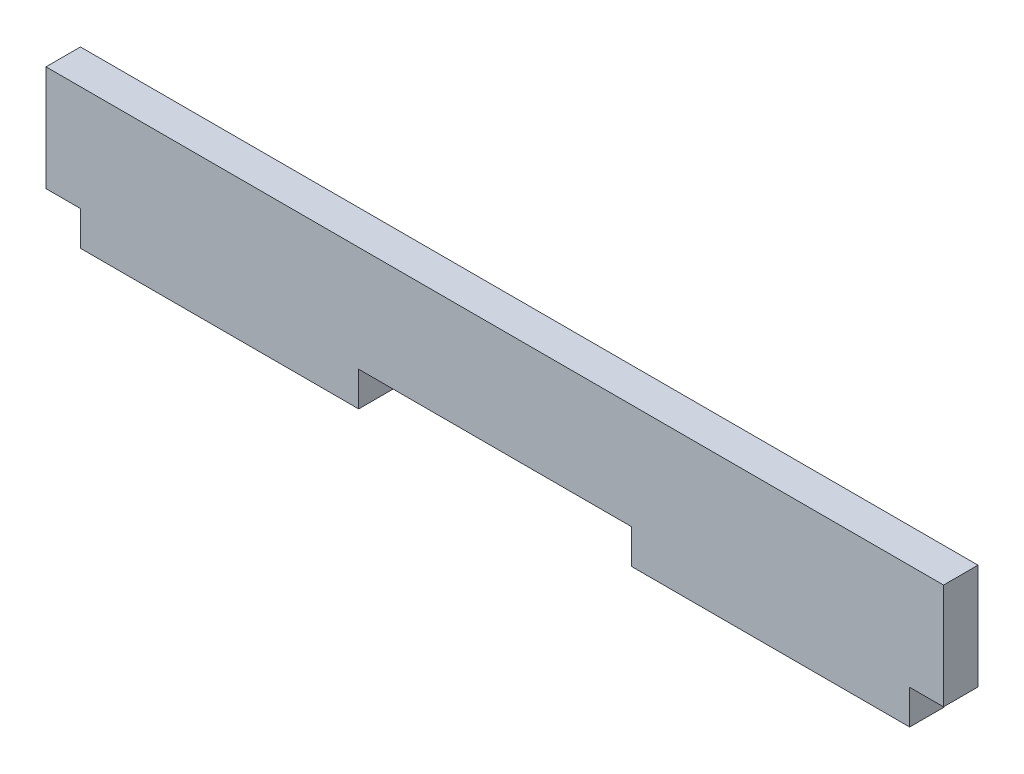
from build123d import *

# Parameters (mm, degrees)
BOSS_EXTRUDE1_DEPTH = 1.5875
BOSS_EXTRUDE2_DEPTH = 3.175


with BuildPart() as part:
    # Sketch1 → Boss-Extrude1 (new body, symmetric)
    with BuildSketch(Plane.XY):
        Polygon((-12.6492, -4.7625), (12.7, -4.7625), (12.7, -7.9375), (38.1508, -7.9375), (38.1508, -4.7625), (41.275, -4.7625), (41.275, 4.7625), (-41.275, 4.7625), (-41.275, -4.7625), (-38.1, -4.7625), (-38.1, -7.9375), (-12.6492, -7.9375), align=None)
    extrude(amount=BOSS_EXTRUDE1_DEPTH, both=True)

    # Sketch2 → Boss-Extrude2 (add)
    with BuildSketch(Plane.XY.offset(1.5875)):
        Polygon((38.2524, -4.8641), (41.3766, -4.8641), (41.3766, 4.8641), (-41.3766, 4.8641), (-41.3766, -4.8641), (-38.2016, -4.8641), (-38.2016, -8.0391), (-12.5476, -8.0391), (-12.5476, -4.8641), (12.5984, -4.8641), (12.5984, -8.0391), (38.2524, -8.0391), align=None)
    extrude(amount=-BOSS_EXTRUDE2_DEPTH)


solid = part.part
